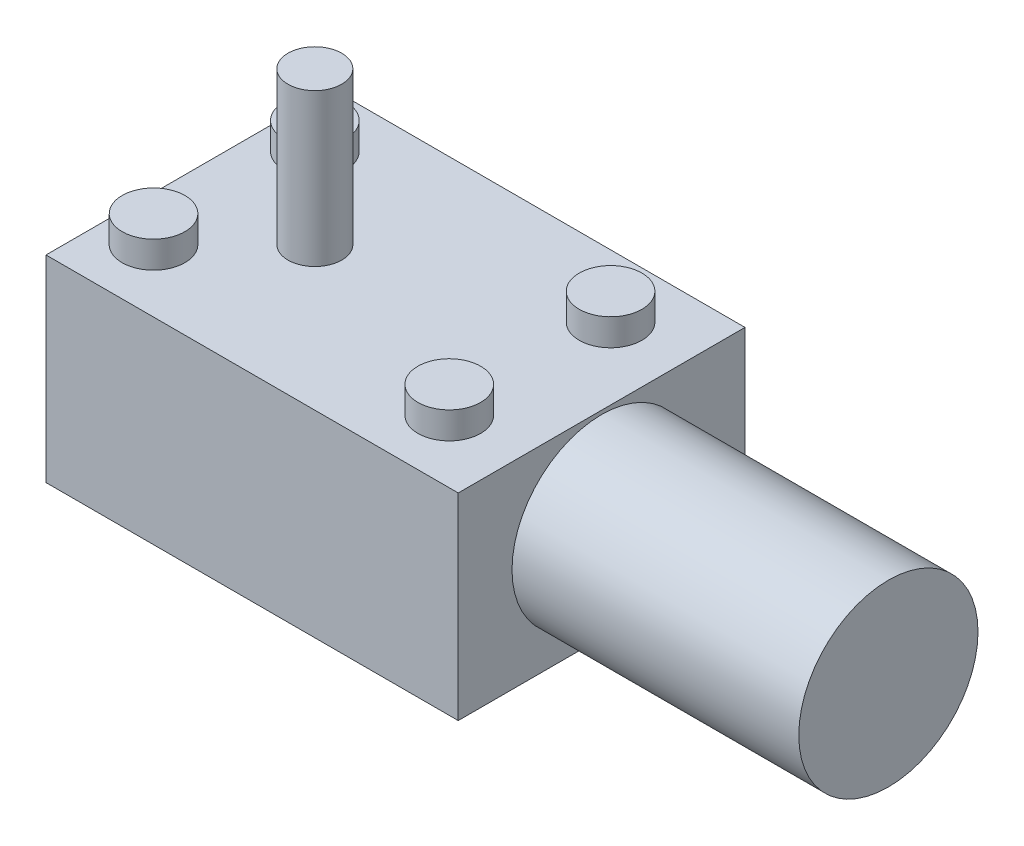
from build123d import *

# Parameters (mm, degrees)
SKETCH1_W           = 46
SKETCH1_H           = 32
BOSS_EXTRUDE1_DEPTH = 22
SKETCH3_R           = 10
BOSS_EXTRUDE3_DEPTH = 32
SKETCH4_R           = 3
BOSS_EXTRUDE4_DEPTH = 17
SKETCH5_R           = 3.5
BOSS_EXTRUDE6_DEPTH = 3


with BuildPart() as part:
    # Sketch1 → Boss-Extrude1 (new body)
    with BuildSketch(Plane(origin=(0, 0, 0), x_dir=(1, 0, 0), z_dir=(0, 1, 0))):
        Rectangle(SKETCH1_W, SKETCH1_H)
    extrude(amount=BOSS_EXTRUDE1_DEPTH)

    # Sketch3 → Boss-Extrude3 (add)
    with BuildSketch(Plane(origin=(23, 0, 0), x_dir=(0, 0, -1), z_dir=(1, 0, 0))):
        with Locations((0, 11.57774751)):
            Circle(SKETCH3_R)
    extrude(amount=BOSS_EXTRUDE3_DEPTH)

    # Sketch4 → Boss-Extrude4 (add)
    with BuildSketch(Plane(origin=(0, 22, 0), x_dir=(1, 0, 0), z_dir=(0, 1, 0))):
        with Locations((-9, 0)):
            Circle(SKETCH4_R)
    extrude(amount=BOSS_EXTRUDE4_DEPTH)

    # Sketch5 → Boss-Extrude6 (add)
    with BuildSketch(Plane(origin=(0, 22, 0), x_dir=(1, 0, 0), z_dir=(0, 1, 0))):
        with Locations((-18, -9)):
            Circle(SKETCH5_R)
        with Locations((15, 9)):
            Circle(SKETCH5_R)
        with Locations((15, -9)):
            Circle(SKETCH5_R)
        with Locations((-18, 9)):
            Circle(SKETCH5_R)
    extrude(amount=BOSS_EXTRUDE6_DEPTH)


solid = part.part
